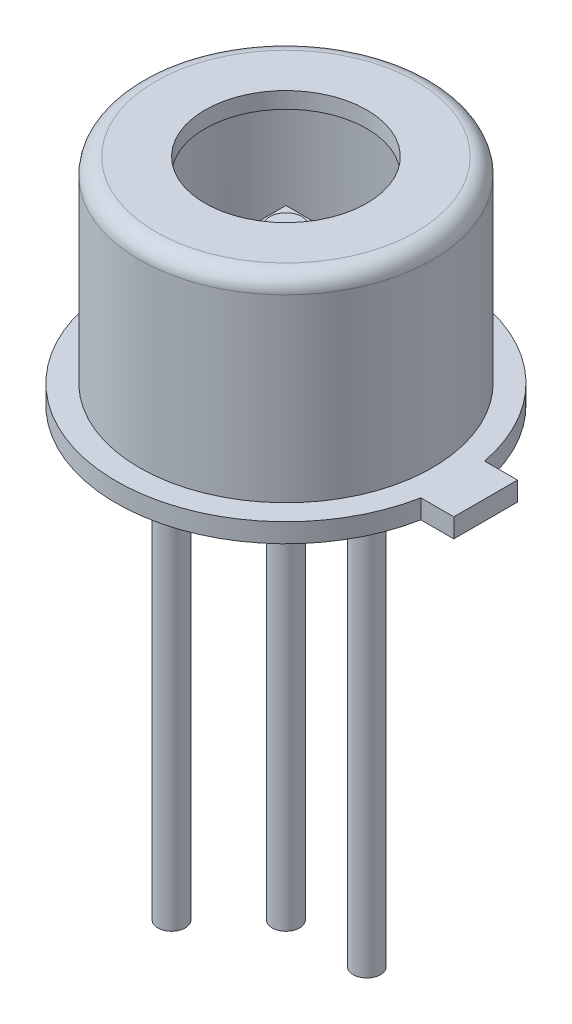
from build123d import *

# Parameters (mm, degrees)
SKETCH2_R           = 2.665
BOSS_EXTRUDE1_DEPTH = 0.046
BOSS_EXTRUDE2_START = -2.34
SKETCH3_W           = 0.75
SKETCH3_H           = 0.75
BOSS_EXTRUDE2_DEPTH = 0.05
SKETCH8_R           = 0.25
BOSS_EXTRUDE6_DEPTH = 0.1
SKETCH5_R           = 0.215
BOSS_EXTRUDE4_DEPTH = 7
SKETCH7_R           = 0.275
BOSS_EXTRUDE5_DEPTH = 0.2
SKETCH10_W          = 0.517324504
SKETCH10_H          = 1
BOSS_EXTRUDE7_DEPTH = 0.3


with BuildPart() as part:
    # Sketch1 → Revolve-Thin2 (revolve)
    with BuildSketch(Plane.XY, mode=Mode.PRIVATE) as revolve_thin2_sk:
        with BuildLine():
            Line((2.665, 0), (2.665, 0.3))
            Line((2.665, 0.3), (2.3, 0.3))
            Line((2.3, 0.3), (2.3, 3.126))
            ThreePointArc((2.3, 3.126), (2.225605122, 3.305605122), (2.046, 3.38))
            Line((2.046, 3.38), (1.27, 3.38))
            Line((1.27, 3.38), (1.27, 3.126))
            Line((1.27, 3.126), (2.046, 3.126))
            Line((2.046, 3.126), (2.046, 0.046))
            Line((2.046, 0.046), (2.411, 0.046))
            Line((2.411, 0.046), (2.411, 0))
            Line((2.411, 0), (2.665, 0))
        make_face()
    revolve(revolve_thin2_sk.sketch.rotate(Axis((0, 0, 0), (0, 1, 0)), 90), axis=Axis((0, 0, 0), (0, 1, 0)))  # turned: the seam where the file's is

    # Sketch2 → Boss-Extrude1 (add)
    with BuildSketch(Plane.XZ):
        with Locations(Location((0, 0, 0), (0, 0, 270))):  # turned: the seam where the file's is
            Circle(SKETCH2_R)
    extrude(amount=-BOSS_EXTRUDE1_DEPTH)

    # Sketch5 → Boss-Extrude4 (add)
    with BuildSketch(Plane.XZ):
        with Locations(Location((0, 0, 0), (0, 0, 90))):  # turned: the seam where the file's is
            Circle(SKETCH5_R)
        with Locations(Location((1.27, 0, 0), (0, 0, 90))):  # turned: the seam where the file's is
            Circle(SKETCH5_R)
        with Locations(Location((-0.898025612, 0.898025612, 0), (0, 0, 90))):  # turned: the seam where the file's is
            Circle(SKETCH5_R)
    extrude(amount=BOSS_EXTRUDE4_DEPTH)

    # Sketch7 → Boss-Extrude5 (add)
    with BuildSketch(Plane.XZ):
        with Locations(Location((-0.898025612, 0.898025612, 0), (0, 0, 90))):  # turned: the seam where the file's is
            Circle(SKETCH7_R)
    extrude(amount=BOSS_EXTRUDE5_DEPTH)

    # Sketch10 → Boss-Extrude7 (add)
    with BuildSketch(Plane.XZ):
        with Locations((2.876337748, 0)):
            Rectangle(SKETCH10_W, SKETCH10_H)
    extrude(amount=-BOSS_EXTRUDE7_DEPTH)


with BuildPart() as body_2:
    # Sketch3 → Boss-Extrude2 (new body)
    with BuildSketch(Plane.XZ.offset(BOSS_EXTRUDE2_START)):
        Rectangle(SKETCH3_W, SKETCH3_H)
    extrude(amount=BOSS_EXTRUDE2_DEPTH)

    # Sketch8 → Boss-Extrude6 (add)
    with BuildSketch(Plane(origin=(0, 2.34, 0), x_dir=(-1, 0, 0), z_dir=(0, 1, 0))):
        with Locations(Location((0, 0, 0), (0, 0, 270))):  # turned: the seam where the file's is
            Circle(SKETCH8_R)
    extrude(amount=BOSS_EXTRUDE6_DEPTH)


solid = Compound([part.part, body_2.part])
